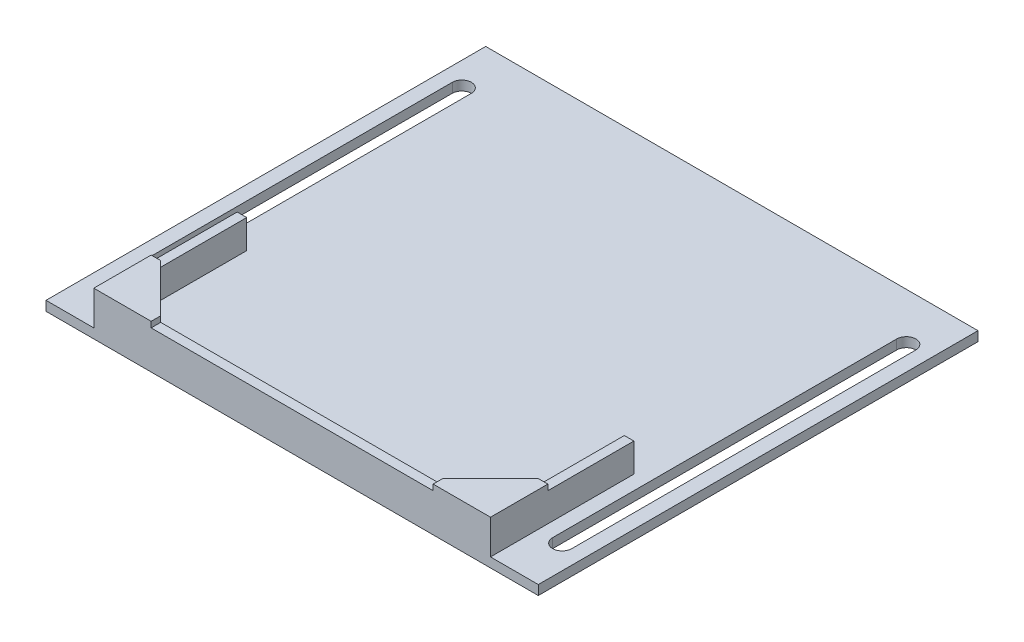
from build123d import *

# Parameters (mm, degrees)
CROQUIS1_W              = 20
CROQUIS1_H              = 20
CROQUIS1_R              = 3
SALIENTE_EXTRUIR1_DEPTH = 5
SALIENTE_EXTRUIR2_DEPTH = 2
SALIENTE_EXTRUIR3_DEPTH = 8
SALIENTE_EXTRUIR4_DEPTH = 1.2
CROQUIS5_W              = 10
CROQUIS5_H              = 92
SALIENTE_EXTRUIR5_DEPTH = 2
CROQUIS6_W              = 83
CROQUIS6_H              = 62
CORTAR_EXTRUIR1_DEPTH   = 6


with BuildPart() as part:
    # Croquis1 → Saliente-Extruir1 (new body)
    with BuildSketch(Plane(origin=(0, 0, 0), x_dir=(1, 0, 0), z_dir=(0, 1, 0))):
        Rectangle(CROQUIS1_W, CROQUIS1_H)
        Circle(CROQUIS1_R, mode=Mode.SUBTRACT)
        with BuildLine():
            Line((2.321637353, -1.9), (-2.321637353, -1.9))
            ThreePointArc((-2.321637353, -1.9), (0, -3), (2.321637353, -1.9))
        make_face()
        with BuildLine():
            Line((-2.321637353, 1.9), (2.321637353, 1.9))
            ThreePointArc((2.321637353, 1.9), (0, 3), (-2.321637353, 1.9))
        make_face()
    extrude(amount=SALIENTE_EXTRUIR1_DEPTH)

    # Croquis2 → Saliente-Extruir2 (add)
    with BuildSketch(Plane(origin=(0, 5, 0), x_dir=(1, 0, 0), z_dir=(0, 1, 0))):
        Polygon((-10, 10), (-39.5, 10), (-39.5, 0), (-39.5, -80), (39.5, -80), (39.5, 0), (39.5, 10), (10, 10), align=None)
    extrude(amount=SALIENTE_EXTRUIR2_DEPTH)

    # Croquis3 → Saliente-Extruir3 (add)
    with BuildSketch(Plane.XZ.offset(-5)):
        Polygon((39.5, 80), (39.5, -10), (41.5, -10), (41.5, 82), (-41.5, 82), (-41.5, -10), (-39.5, -10), (-39.5, 80), align=None)
    extrude(amount=-SALIENTE_EXTRUIR3_DEPTH)

    # Croquis4 → Saliente-Extruir4 (add)
    with BuildSketch(Plane(origin=(0, 13, 0), x_dir=(1, 0, 0), z_dir=(0, 1, 0))):
        Polygon((-39.5, -80), (-29.5, -80), (-39.5, -70), align=None)
        Polygon((-29.5, -82), (-29.5, -80), (-39.5, -80), (-39.5, -70), (-41.5, -70), (-41.5, -82), align=None)
        Polygon((39.5, -70), (29.5, -80), (39.5, -80), align=None)
        Polygon((39.5, -80), (29.5, -80), (29.5, -82), (41.5, -82), (41.5, -70), (39.5, -70), align=None)
    extrude(amount=SALIENTE_EXTRUIR4_DEPTH)

    # Croquis5 → Saliente-Extruir5 (add)
    with BuildSketch(Plane.XZ.offset(-5)):
        with Locations((-46.5, 36)):
            Rectangle(CROQUIS5_W, CROQUIS5_H)
        with BuildLine():
            Line((-48.5, 0), (-48.5, 72))
            ThreePointArc((-48.5, 72), (-46.5, 74), (-44.5, 72))
            Line((-44.5, 72), (-44.5, 0))
            ThreePointArc((-44.5, 0), (-46.5, -2), (-48.5, 0))
        make_face(mode=Mode.SUBTRACT)
        with Locations((46.5, 36)):
            Rectangle(CROQUIS5_W, CROQUIS5_H)
        with BuildLine():
            Line((48.5, 0), (48.5, 72))
            ThreePointArc((48.5, 72), (46.5, 74), (44.5, 72))
            Line((44.5, 72), (44.5, 0))
            ThreePointArc((44.5, 0), (46.5, -2), (48.5, 0))
        make_face(mode=Mode.SUBTRACT)
    extrude(amount=-SALIENTE_EXTRUIR5_DEPTH)

    # Croquis6 → Cortar-Extruir1 (cut)
    with BuildSketch(Plane(origin=(0, 13, 0), x_dir=(1, 0, 0), z_dir=(0, 1, 0))):
        with Locations((0, -21)):
            Rectangle(CROQUIS6_W, CROQUIS6_H)
    extrude(amount=-CORTAR_EXTRUIR1_DEPTH, mode=Mode.SUBTRACT)


solid = part.part
